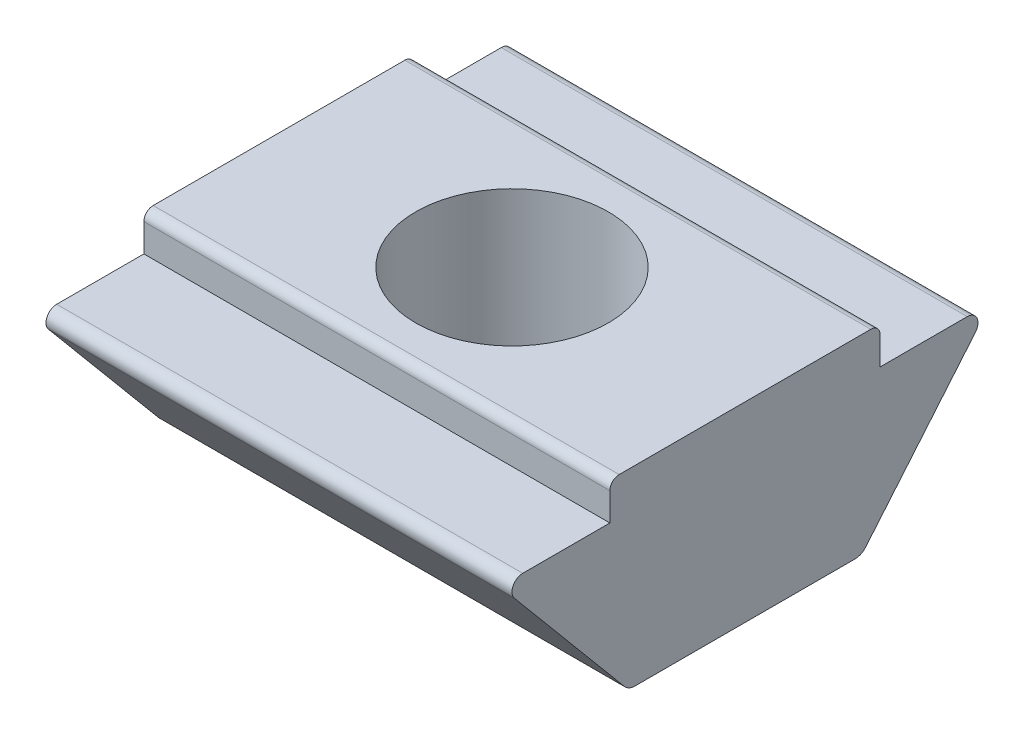
from build123d import *

# Parameters (mm, degrees)
BOSS_EXTRUDE1_DEPTH = 10
FILLET1_R           = 0.3
FILLET2_R           = 0.2
TAPPED_HOLE1_D      = 4.134


with BuildPart() as part:
    # Sketch1 → Boss-Extrude1 (new body)
    with BuildSketch(Plane(origin=(-5, 0, 0), x_dir=(0, 0, -1), z_dir=(1, 0, 0))):
        with BuildLine():
            Line((2.5, -4.1), (-2.5, -4.1))
            Line((-2.5, -4.1), (-4.94636223, -1.177635916))
            ThreePointArc((-4.94636223, -1.177635916), (-4.978394171, -0.932676469), (-4.77, -0.8))
            Line((-4.77, -0.8), (-2.9, -0.8))
            Line((-2.9, -0.8), (-2.9, 0))
            Line((-2.9, 0), (2.9, 0))
            Line((2.9, 0), (2.9, -0.8))
            Line((2.9, -0.8), (4.77, -0.8))
            ThreePointArc((4.77, -0.8), (4.978394171, -0.932676469), (4.94636223, -1.177635916))
            Line((4.94636223, -1.177635916), (2.5, -4.1))
        make_face()
    extrude(amount=BOSS_EXTRUDE1_DEPTH)

    # Fillet1
    fillet1_edges = [part.edges().sort_by_distance(p)[0] for p in [
        (0, -4.1, -2.5),
        (0, -4.1, 2.5),
    ]]
    fillet(fillet1_edges, radius=FILLET1_R)

    # Fillet2
    fillet2_edges = [part.edges().sort_by_distance(p)[0] for p in [
        (0, 0, 2.9),
        (0, 0, -2.9),
    ]]
    fillet(fillet2_edges, radius=FILLET2_R)

    # Tapped Hole1 (through all)
    with Locations(Plane(origin=(0, 0, 0), x_dir=(1, 0, 0), z_dir=(0, 1, 0))):
        with Locations((0, 0)):
            Hole(TAPPED_HOLE1_D / 2)


solid = part.part
